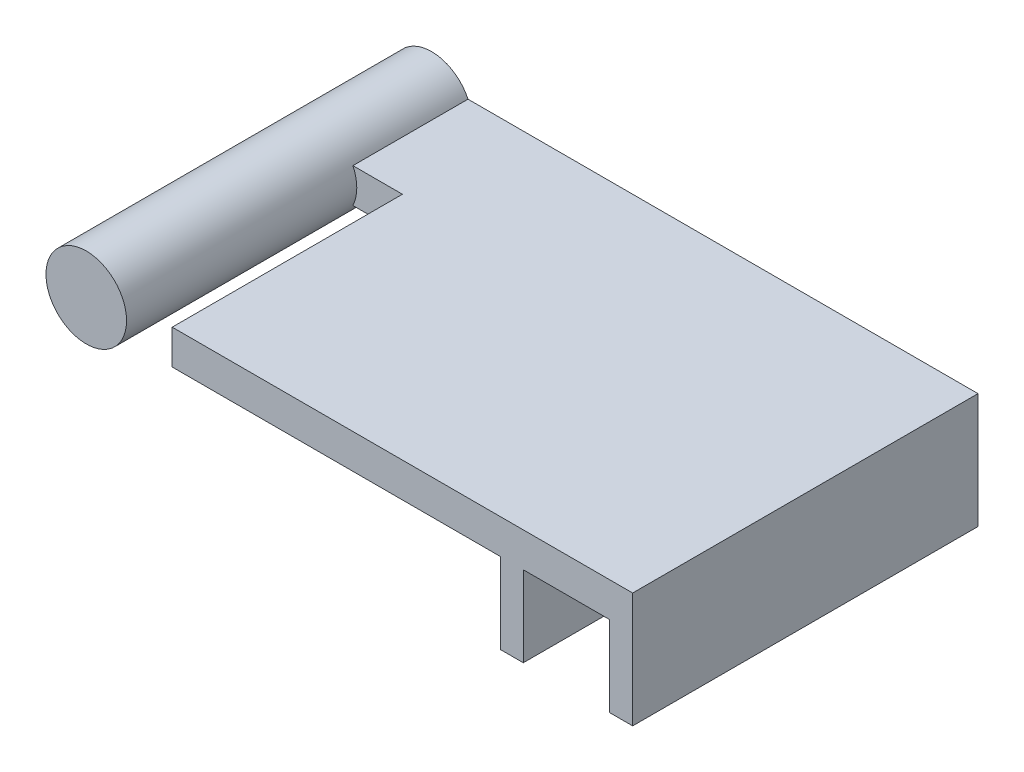
from build123d import *

# Parameters (mm, degrees)
BOSS_EXTRUDE1_DEPTH = 30
SKETCH3_W           = 6
SKETCH3_H           = 3
BOSS_EXTRUDE2_DEPTH = 10
SKETCH4_R           = 3.5
BOSS_EXTRUDE3_DEPTH = 30


with BuildPart() as part:
    # Sketch2 → Boss-Extrude1 (new body)
    with BuildSketch(Plane.XY):
        Polygon((-20, -1.5), (8.5, -1.5), (8.5, -8.5), (10.5, -8.5), (10.5, -1.5), (18, -1.5), (18, -8.5), (20, -8.5), (20, -1.5), (20, 1.5), (-20, 1.5), align=None)
    extrude(amount=BOSS_EXTRUDE1_DEPTH)

    # Sketch3 → Boss-Extrude2 (add)
    with BuildSketch(Plane.XY):
        with Locations((-23, 0)):
            Rectangle(SKETCH3_W, SKETCH3_H)
    extrude(amount=BOSS_EXTRUDE2_DEPTH)

    # Sketch4 → Boss-Extrude3 (add)
    with BuildSketch(Plane.XY):
        with Locations((-27.465142918, 0)):
            Circle(SKETCH4_R)
    extrude(amount=BOSS_EXTRUDE3_DEPTH)


solid = part.part
